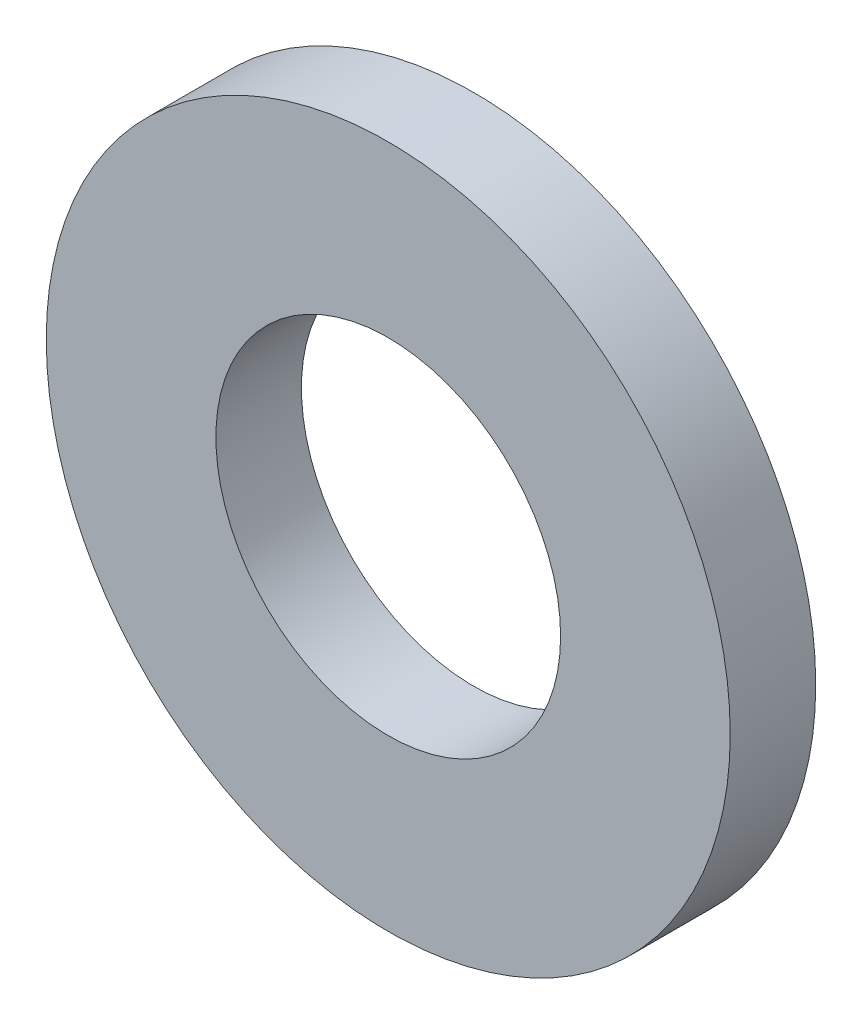
from build123d import *

# Parameters (mm, degrees)
SKETCH1_R           = 12.7
SKETCH1_R_2         = 6.4008
BOSS_EXTRUDE1_DEPTH = 3.175


with BuildPart() as part:
    # Sketch1 → Boss-Extrude1 (new body)
    with BuildSketch(Plane.XY):
        Circle(SKETCH1_R)
        Circle(SKETCH1_R_2, mode=Mode.SUBTRACT)
    extrude(amount=BOSS_EXTRUDE1_DEPTH)


solid = part.part
